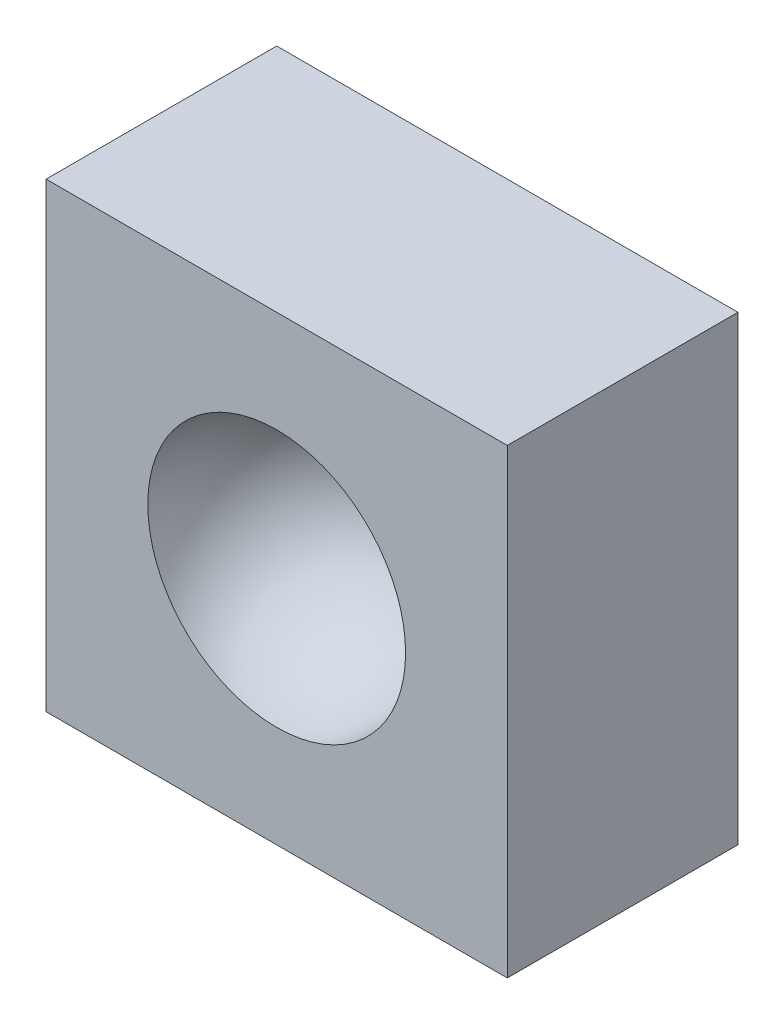
from build123d import *

# Parameters (mm, degrees)
ESBO_O1_W       = 100
ESBO_O1_H       = 100
EXTRUS_O1_DEPTH = 50


with BuildPart() as part:
    # Esboço1 → Extrusão1 (new body)
    with BuildSketch(Plane.XY):
        Rectangle(ESBO_O1_W, ESBO_O1_H)
    extrude(amount=EXTRUS_O1_DEPTH)

    # Esboço2 → Corte-Revolução1 (revolve, cut)
    with BuildSketch(Plane.XY.offset(50)):
        with BuildLine():
            Line((-27.945356346, 0), (27.945356346, 0))
            ThreePointArc((27.945356346, 0), (0, 27.945356346), (-27.945356346, 0))
        make_face()
    revolve(axis=Axis((-27.945356346, 0, 50), (1, 0, 0)), mode=Mode.SUBTRACT)


solid = part.part
